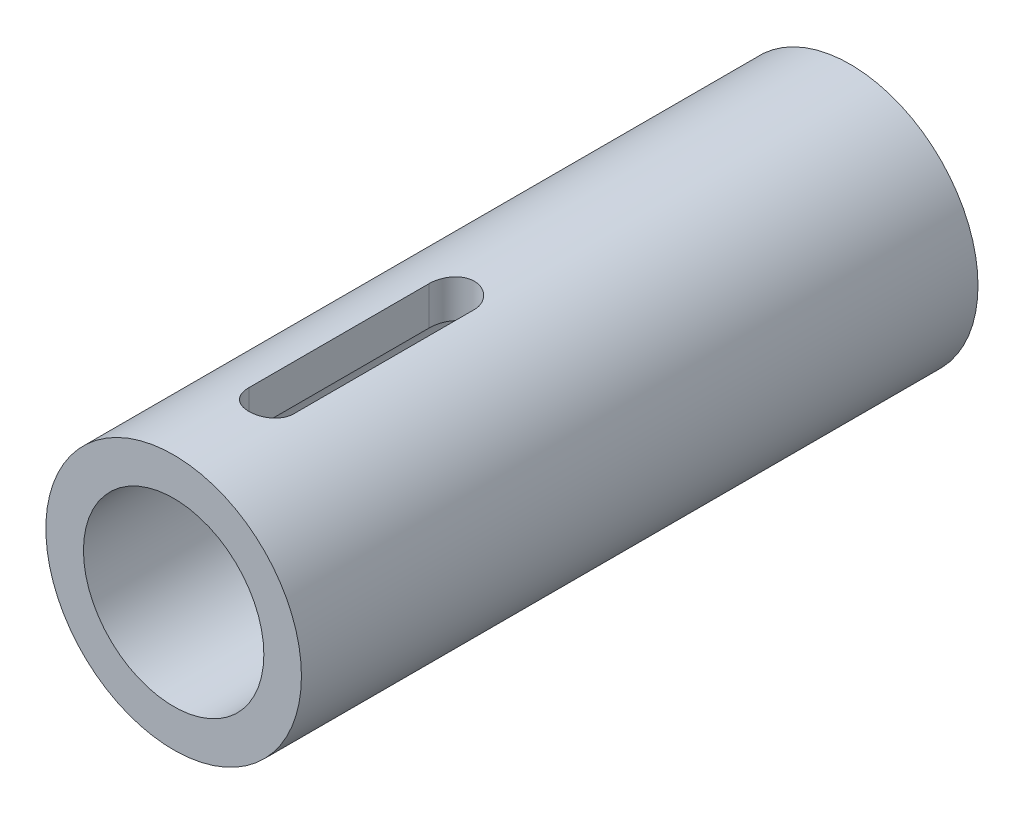
from build123d import *

# Parameters (mm, degrees)
SKETCH1_R           = 8.5
SKETCH1_R_2         = 6
BOSS_EXTRUDE1_DEPTH = 45
CUT_EXTRUDE1_REACH  = 19


with BuildPart() as part:
    # Sketch1 → Boss-Extrude1 (new body)
    with BuildSketch(Plane.XY):
        Circle(SKETCH1_R)
        Circle(SKETCH1_R_2, mode=Mode.SUBTRACT)
    extrude(amount=BOSS_EXTRUDE1_DEPTH)

    # Sketch2 → Cut-Extrude1 (cut, up to next)
    with BuildSketch(Plane(origin=(0, 8.5, 0), x_dir=(-1, 0, 0), z_dir=(0, 1, 0)), mode=Mode.PRIVATE) as cut_extrude1_sk1:
        with BuildLine():
            Line((1.5, 38.5), (1.5, 26.5))
            ThreePointArc((1.5, 26.5), (0, 25), (-1.5, 26.5))
            Line((-1.5, 26.5), (-1.5, 38.5))
            ThreePointArc((-1.5, 38.5), (0, 40), (1.5, 38.5))
        make_face()
    cut_extrude1_tool1 = extrude(cut_extrude1_sk1.sketch, amount=-CUT_EXTRUDE1_REACH, mode=Mode.PRIVATE) & part.part
    add(cut_extrude1_tool1.solids().sort_by_distance((0, 8.5, 32.5))[0], mode=Mode.SUBTRACT)


solid = part.part
